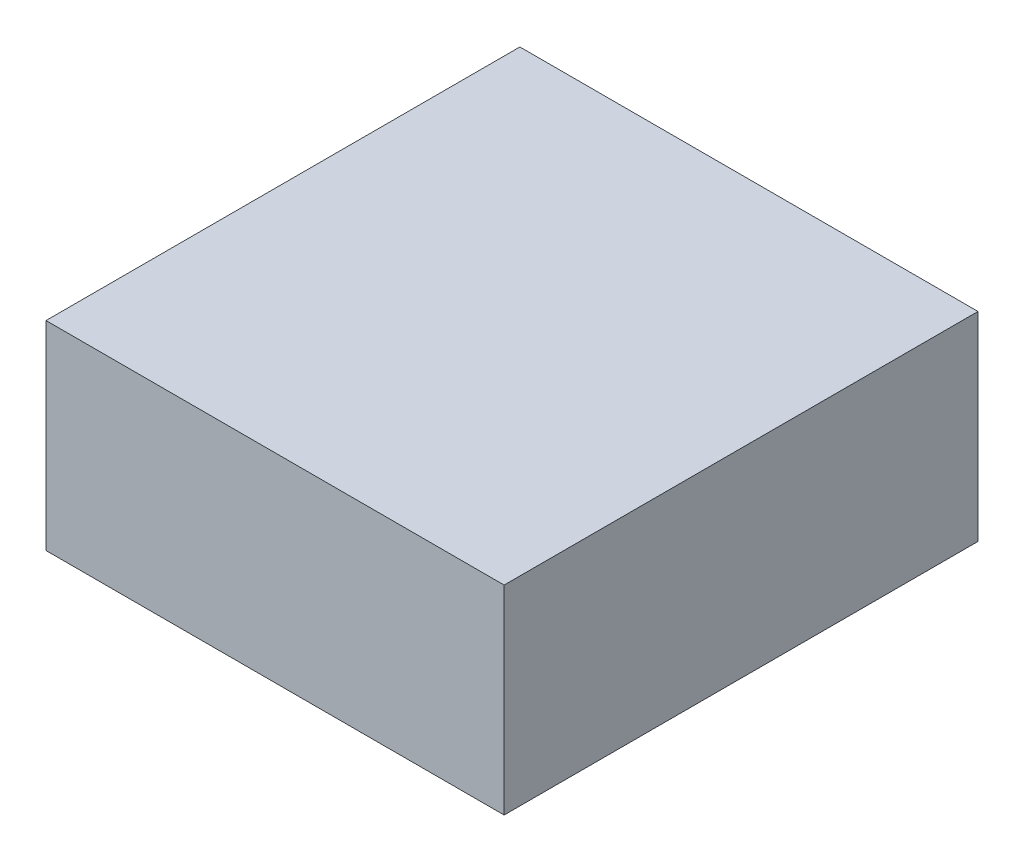
from build123d import *

# Parameters (mm, degrees)
SKETCH1_W           = 110.998
SKETCH1_H           = 48.26
BOSS_EXTRUDE1_DEPTH = 114.808


with BuildPart() as part:
    # Sketch1 → Boss-Extrude1 (new body)
    with BuildSketch(Plane.XY):
        with Locations((55.499, 24.13)):
            Rectangle(SKETCH1_W, SKETCH1_H)
    extrude(amount=BOSS_EXTRUDE1_DEPTH)


solid = part.part
